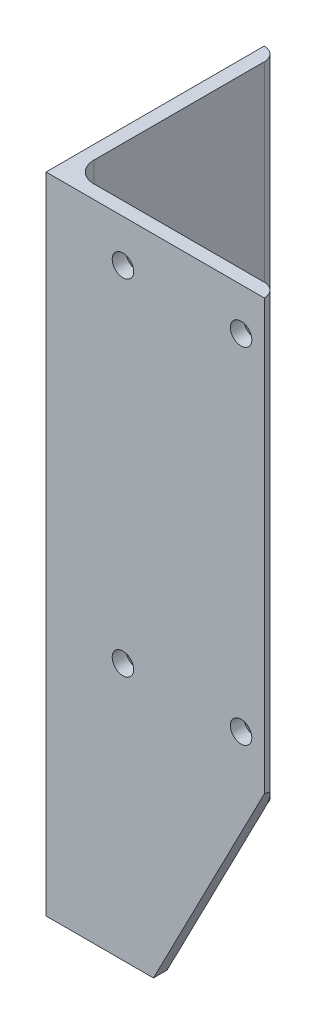
from build123d import *

# Parameters (mm, degrees)
HIERRO_ANGULAR_2_X_2_X_0_125_1_DEPTH = 150
CORTAR_EXTRUIR1_DEPTH                = 10
CORTAR_EXTRUIR2_REACH                = 168.317
CROQUIS4_R                           = 2.5


with BuildPart() as part:
    # Sketch1 → Hierro angular 2 X 2 X 0.125(1) (new body)
    with BuildSketch(Plane(origin=(0, 0, 0), x_dir=(1, 0, 0), z_dir=(0, 1, 0))):
        with BuildLine():
            Line((0, 0), (0, 50.8))
            Line((0, 50.8), (0.00508, 50.8))
            ThreePointArc((0.00508, 50.8), (2.246551928, 49.871551928), (3.175, 47.63008))
            Line((3.175, 47.63008), (3.175, 7.9375))
            ThreePointArc((3.175, 7.9375), (4.569903955, 4.569903955), (7.9375, 3.175))
            Line((7.9375, 3.175), (47.63008, 3.175))
            ThreePointArc((47.63008, 3.175), (49.871551928, 2.246551928), (50.8, 0.00508))
            Line((50.8, 0.00508), (50.8, 0))
            Line((50.8, 0), (0, 0))
        make_face()
    extrude(amount=HIERRO_ANGULAR_2_X_2_X_0_125_1_DEPTH)

    # Croquis3 → Cortar-Extruir1 (cut)
    with BuildSketch(Plane.XY):
        Polygon((25, 0), (50.8, 50), (50.8, 0), align=None)
    extrude(amount=-CORTAR_EXTRUIR1_DEPTH, mode=Mode.SUBTRACT)

    # Cortar-Extruir2: up to this face of the body (flat: up to its plane)
    cortar_extruir2_end = Plane(part.part.faces().sort_by_distance((26.665136317, 80.490198143, -3.175))[0])
    # Croquis4 → Cortar-Extruir2 (cut, up to the picked face)
    with BuildSketch(Plane.XY, mode=Mode.PRIVATE) as cortar_extruir2_sk1:
        with Locations((17.9, 140.12)):
            Circle(CROQUIS4_R)
    cortar_extruir2_tool1 = split(extrude(cortar_extruir2_sk1.sketch, amount=-CORTAR_EXTRUIR2_REACH, mode=Mode.PRIVATE), bisect_by=cortar_extruir2_end, keep=Keep.BOTH, mode=Mode.PRIVATE)
    # Croquis4 → Cortar-Extruir2 (cut, up to the picked face)
    with BuildSketch(Plane.XY, mode=Mode.PRIVATE) as cortar_extruir2_sk2:
        with Locations((45.4, 140.12)):
            Circle(CROQUIS4_R)
    cortar_extruir2_tool2 = split(extrude(cortar_extruir2_sk2.sketch, amount=-CORTAR_EXTRUIR2_REACH, mode=Mode.PRIVATE), bisect_by=cortar_extruir2_end, keep=Keep.BOTH, mode=Mode.PRIVATE)
    # Croquis4 → Cortar-Extruir2 (cut, up to the picked face)
    with BuildSketch(Plane.XY, mode=Mode.PRIVATE) as cortar_extruir2_sk3:
        with Locations((17.9, 59.87)):
            Circle(CROQUIS4_R)
    cortar_extruir2_tool3 = split(extrude(cortar_extruir2_sk3.sketch, amount=-CORTAR_EXTRUIR2_REACH, mode=Mode.PRIVATE), bisect_by=cortar_extruir2_end, keep=Keep.BOTH, mode=Mode.PRIVATE)
    # Croquis4 → Cortar-Extruir2 (cut, up to the picked face)
    with BuildSketch(Plane.XY, mode=Mode.PRIVATE) as cortar_extruir2_sk4:
        with Locations((45.4, 59.87)):
            Circle(CROQUIS4_R)
    cortar_extruir2_tool4 = split(extrude(cortar_extruir2_sk4.sketch, amount=-CORTAR_EXTRUIR2_REACH, mode=Mode.PRIVATE), bisect_by=cortar_extruir2_end, keep=Keep.BOTH, mode=Mode.PRIVATE)
    add(cortar_extruir2_tool1.solids().sort_by(Axis((17.9, 140.12, 0), (0, 0, -1)))[0], mode=Mode.SUBTRACT)
    add(cortar_extruir2_tool2.solids().sort_by(Axis((45.4, 140.12, 0), (0, 0, -1)))[0], mode=Mode.SUBTRACT)
    add(cortar_extruir2_tool3.solids().sort_by(Axis((17.9, 59.87, 0), (0, 0, -1)))[0], mode=Mode.SUBTRACT)
    add(cortar_extruir2_tool4.solids().sort_by(Axis((45.4, 59.87, 0), (0, 0, -1)))[0], mode=Mode.SUBTRACT)


solid = part.part
